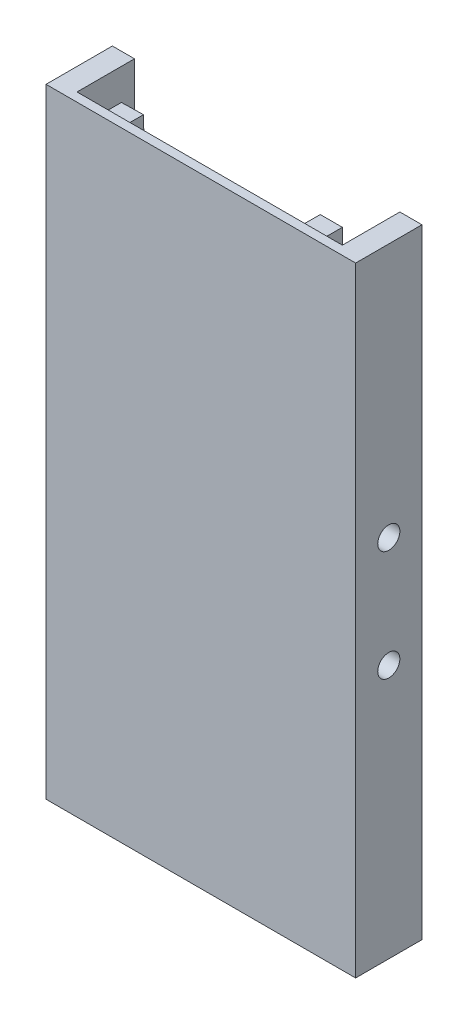
from build123d import *

# Parameters (mm, degrees)
SKETCH2_W           = 70
SKETCH2_H           = 140
BOSS_EXTRUDE1_DEPTH = 15
SKETCH3_W           = 60
SKETCH3_H           = 130
CUT_EXTRUDE1_DEPTH  = 12.5
SKETCH4_W           = 60
SKETCH4_H           = 13
CUT_EXTRUDE2_DEPTH  = 141
SKETCH7_R           = 2.5
CUT_EXTRUDE5_DEPTH  = 71
CUT_REVOLVE1_ANGLE  = 30
SKETCH36_W          = 5
SKETCH36_H          = 5
BOSS_EXTRUDE2_DEPTH = 5


with BuildPart() as part:
    # Sketch2 → Boss-Extrude1 (new body)
    with BuildSketch(Plane.XY):
        with Locations((35, 368.888888889)):
            Rectangle(SKETCH2_W, SKETCH2_H)
    extrude(amount=-BOSS_EXTRUDE1_DEPTH)

    # Sketch3 → Cut-Extrude1 (cut)
    with BuildSketch(Plane(origin=(0, 0, -15), x_dir=(-1, 0, 0), z_dir=(0, 0, -1))):
        with Locations((-35, 368.888888889)):
            Rectangle(SKETCH3_W, SKETCH3_H)
    extrude(amount=-CUT_EXTRUDE1_DEPTH, mode=Mode.SUBTRACT)

    # Sketch4 → Cut-Extrude2 (cut, through all)
    with BuildSketch(Plane(origin=(0, 438.888888889, 0), x_dir=(1, 0, 0), z_dir=(0, 1, 0))):
        with Locations((35, 8.5)):
            Rectangle(SKETCH4_W, SKETCH4_H)
    extrude(amount=-CUT_EXTRUDE2_DEPTH, mode=Mode.SUBTRACT)

    # Sketch7 → Cut-Extrude5 (cut, through all)
    with BuildSketch(Plane.ZY):
        with Locations((-7.5, 381.388888889)):
            Circle(SKETCH7_R)
        with Locations((-7.5, 356.388888889)):
            Circle(SKETCH7_R)
    extrude(amount=-CUT_EXTRUDE5_DEPTH, mode=Mode.SUBTRACT)

    # Sketch32 → Cut-Revolve1 (revolve, cut)
    with BuildSketch(Plane.XZ.offset(-298.888888889)):
        with BuildLine():
            Line((33.5, -2), (36.5, -2))
            ThreePointArc((36.5, -2), (35, -0.5), (33.5, -2))
        make_face()
    revolve(axis=Axis((33.5, 298.888888889, -2), (-1, 0, 0)), revolution_arc=CUT_REVOLVE1_ANGLE, mode=Mode.SUBTRACT)

    # Sketch36 → Boss-Extrude2 (add)
    with BuildSketch(Plane(origin=(0, 0, -2), x_dir=(-1, 0, 0), z_dir=(0, 0, -1))):
        with Locations((-57.5, 434.888888889)):
            Rectangle(SKETCH36_W, SKETCH36_H)
        Polygon((-10.145008864, 431.85472827), (-15.143861036, 431.961858829), (-15.036730477, 436.960711001), (-10.037878305, 436.853580442), align=None)
        Polygon((-10.145008864, 305.923049508), (-15.143861036, 305.815918949), (-15.036730477, 300.817066777), (-10.037878305, 300.924197336), align=None)
        with Locations((-57.5, 302.888888889)):
            Rectangle(SKETCH36_W, SKETCH36_H)
    extrude(amount=BOSS_EXTRUDE2_DEPTH)


solid = part.part
